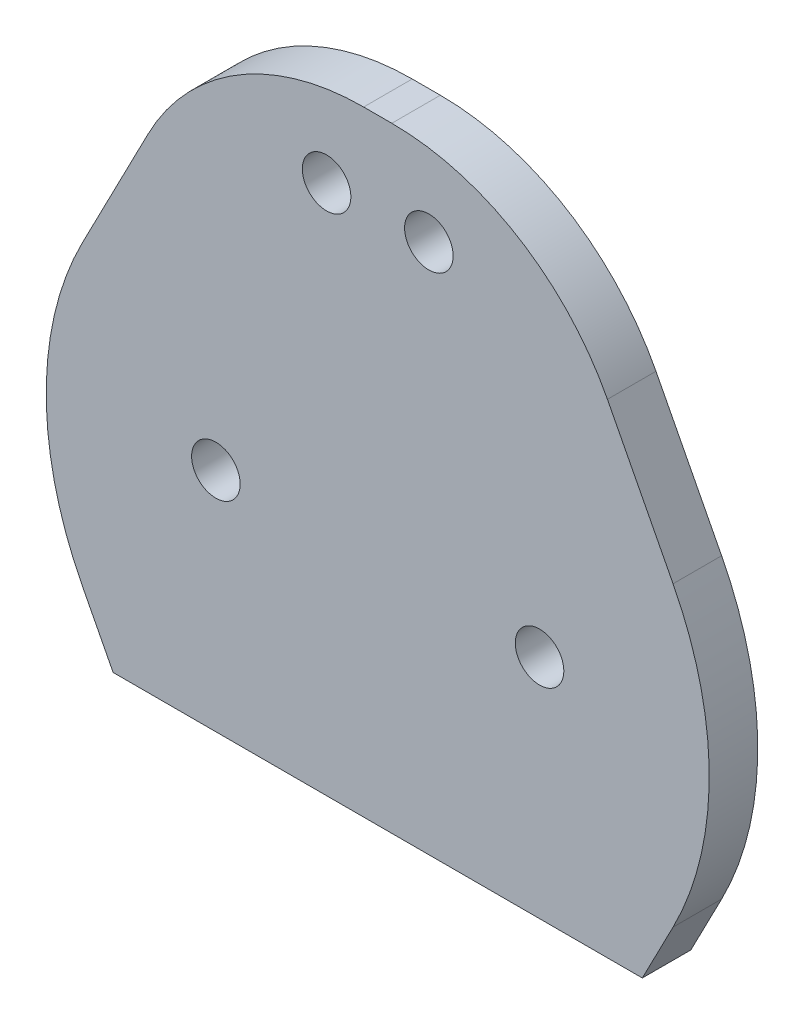
from build123d import *

# Parameters (mm, degrees)
SCHIZZO1_W                   = 46
SCHIZZO1_H                   = 38
SCHIZZO1_R                   = 1.5
ESTRUSIONE_ESTRUSIONE3_DEPTH = 3
TAGLIO_ESTRUSIONE1_DEPTH     = 3
RACCORDO1_R                  = 15
RACCORDO2_R                  = 15
RACCORDO3_R                  = 20
RACCORDO4_R                  = 20


with BuildPart() as part:
    # Schizzo1 → Estrusione-Estrusione3 (new body)
    with BuildSketch(Plane.XY):
        with Locations((-10.000402867, 5)):
            Rectangle(SCHIZZO1_W, SCHIZZO1_H)
        with Locations((-6.840402867, 18.793852416)):
            Circle(SCHIZZO1_R, mode=Mode.SUBTRACT)
        Circle(SCHIZZO1_R, mode=Mode.SUBTRACT)
        with Locations((-20.000805733, 0)):
            Circle(SCHIZZO1_R, mode=Mode.SUBTRACT)
        with Locations((-13.160402867, 18.793852416)):
            Circle(SCHIZZO1_R, mode=Mode.SUBTRACT)
    extrude(amount=ESTRUSIONE_ESTRUSIONE3_DEPTH)

    # Schizzo4 → Taglio-Estrusione1 (cut)
    with BuildSketch(Plane.XY.offset(3)):
        Polygon((-33.000402867, -1.13961018), (-20.000402867, 24), (-33.000402867, 24), align=None)
        Polygon((12.999597133, 24), (-0.000402867, 24), (12.999597133, -1.13961018), align=None)
        Polygon((-26.350137947, -14), (-33.000402867, -1.13961018), (-33.000402867, -14), align=None)
        Polygon((12.999597133, -14), (12.999597133, -1.13961018), (6.349332214, -14), align=None)
    extrude(amount=-TAGLIO_ESTRUSIONE1_DEPTH, mode=Mode.SUBTRACT)

    # Raccordo1
    raccordo1_edges = [part.edges().sort_by_distance(p)[0] for p in [
        (-0.000402867, 24, 1.5),
    ]]
    fillet(raccordo1_edges, radius=RACCORDO1_R)

    # Raccordo2
    raccordo2_edges = [part.edges().sort_by_distance(p)[0] for p in [
        (-20.000402867, 24, 1.5),
    ]]
    fillet(raccordo2_edges, radius=RACCORDO2_R)

    # Raccordo3
    raccordo3_edges = [part.edges().sort_by_distance(p)[0] for p in [
        (12.999597133, -1.13961018, 1.5),
    ]]
    fillet(raccordo3_edges, radius=RACCORDO3_R)

    # Raccordo4
    raccordo4_edges = [part.edges().sort_by_distance(p)[0] for p in [
        (-33.000402867, -1.13961018, 1.5),
    ]]
    fillet(raccordo4_edges, radius=RACCORDO4_R)


solid = part.part
